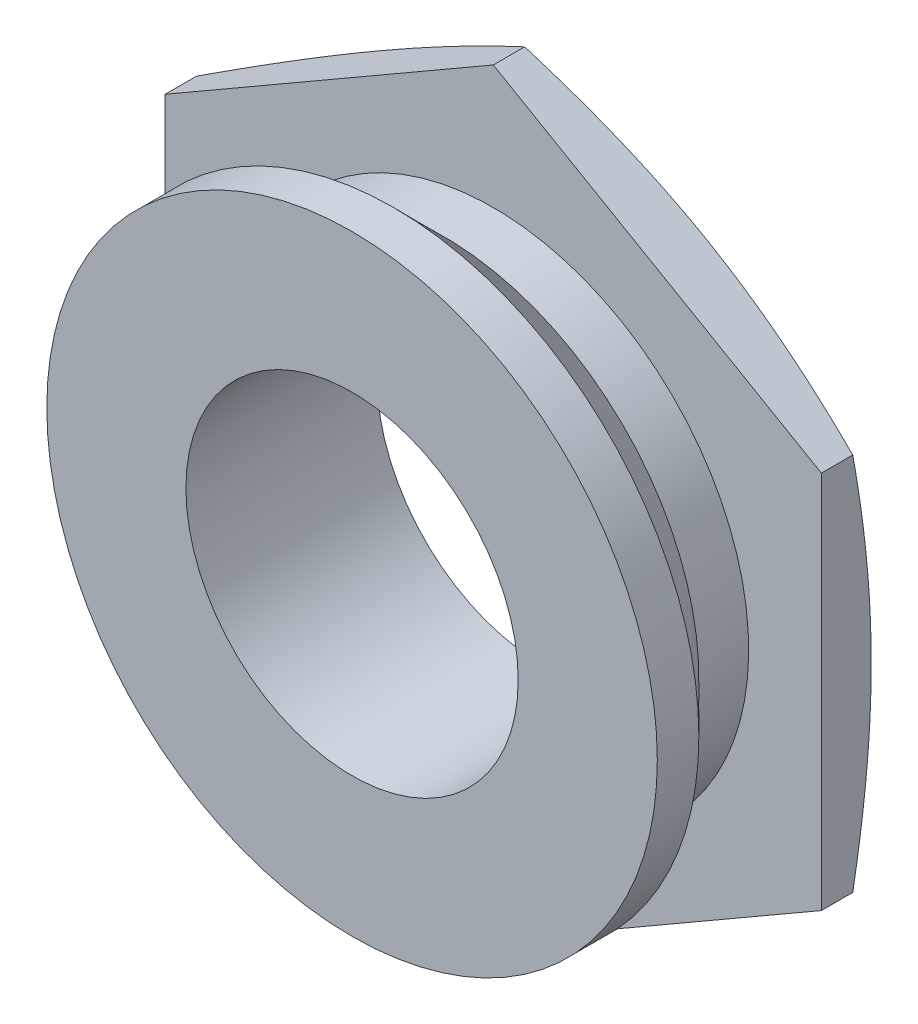
from build123d import *

# Parameters (mm, degrees)
BOSS_EXTRUDE1_DEPTH = 0.6
SKETCH6_W           = 2.3
SKETCH6_H           = 2


with BuildPart() as part:
    # Sketch1 → Revolve1 (revolve)
    with BuildSketch(Plane.ZY):
        Polygon((0, 3.075), (0.6, 3.075), (1.2, 3.675), (1.7, 3.675), (1.7, 0), (0, 0), (-0.6, 0), (-0.6, 3.95), (0, 3.95), align=None)
    revolve(axis=Axis((0, 0, 1.7), (0, 0, -1)))

    # Sketch3 → Boss-Extrude1 (add)
    with BuildSketch(Plane(origin=(0, 0, -0.6), x_dir=(-1, 0, 0), z_dir=(0, 0, -1))):
        Polygon((0, 4.561067127), (-3.95, 2.280533563), (-3.95, -2.280533563), (0, -4.561067127), (3.95, -2.280533563), (3.95, 2.280533563), align=None)
    extrude(amount=-BOSS_EXTRUDE1_DEPTH)

    # Sketch10 → Cut-Revolve4 (revolve, cut)
    with BuildSketch(Plane(origin=(0, 0, 0), x_dir=(0, 0, -1), z_dir=(1, 0, 0))):
        Polygon((0.377589755, 4.561067127), (0.6, 4.561067127), (0.6, 3.95), align=None)
    revolve(axis=Axis((0, 0, -0.6), (0, 0, 1)), mode=Mode.SUBTRACT)

    # Sketch6 → Cut-Revolve2 (revolve, cut)
    with BuildSketch(Plane(origin=(0, 0, 0), x_dir=(0, 0, -1), z_dir=(1, 0, 0))):
        with Locations((-0.55, 1)):
            Rectangle(SKETCH6_W, SKETCH6_H)
    revolve(axis=Axis((0, 0, -0.6), (0, 0, 1)), mode=Mode.SUBTRACT)


solid = part.part
